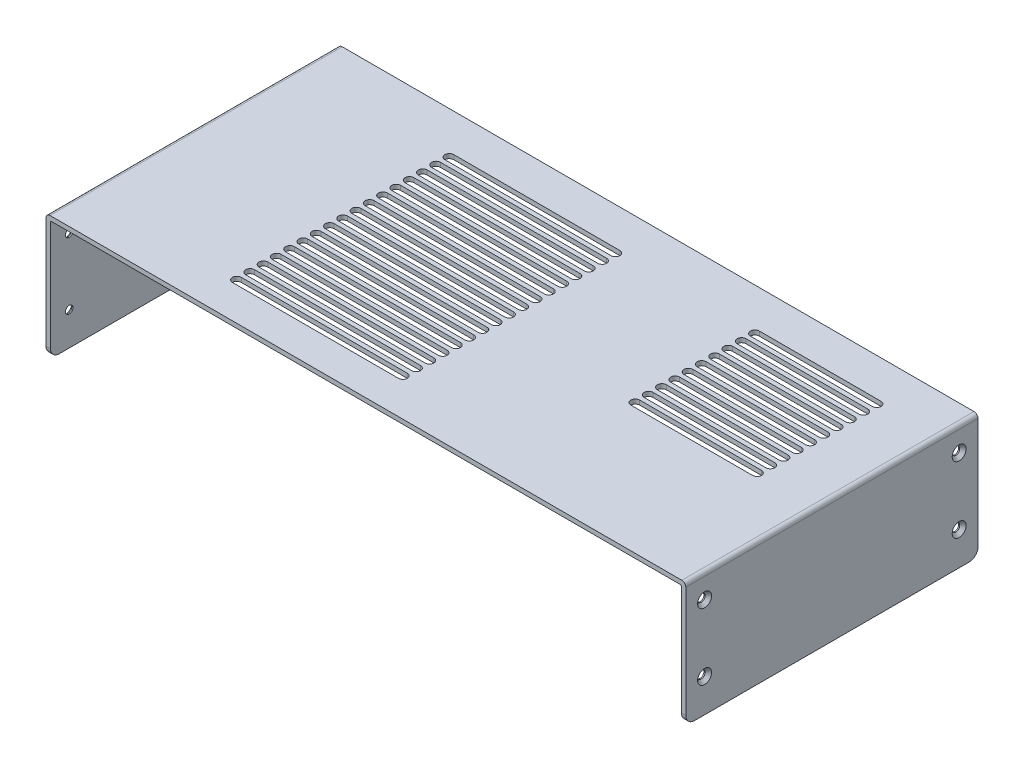
from build123d import *

# Parameters (mm, degrees)
BOSS_EXTRUDE1_DEPTH                             = 132
CSK_FOR_M3_FLAT_HEAD_MACHINE_SCREW1_D           = 3.4
CSK_FOR_M3_FLAT_HEAD_MACHINE_SCREW1_DEPTH       = 5
CSK_FOR_M3_FLAT_HEAD_MACHINE_SCREW1_CSINK_D     = 6.3
CSK_FOR_M3_FLAT_HEAD_MACHINE_SCREW1_CSINK_ANGLE = 90
CSK_FOR_M3_FLAT_HEAD_MACHINE_SCREW1_TIP         = 1.021463052
CSK_FOR_M3_FLAT_HEAD_MACHINE_SCREW2_D           = 3.4
CSK_FOR_M3_FLAT_HEAD_MACHINE_SCREW2_DEPTH       = 5
CSK_FOR_M3_FLAT_HEAD_MACHINE_SCREW2_CSINK_D     = 6.3
CSK_FOR_M3_FLAT_HEAD_MACHINE_SCREW2_CSINK_ANGLE = 90
CSK_FOR_M3_FLAT_HEAD_MACHINE_SCREW2_TIP         = 1.021463052
CUT_EXTRUDE1_DEPTH                              = 5
LPATTERN1_COUNT                                 = 17
LPATTERN1_PITCH                                 = 6
CUT_EXTRUDE2_DEPTH                              = 200
LPATTERN2_COUNT                                 = 10
LPATTERN2_PITCH                                 = 6
FILLET1_R                                       = 4


with BuildPart() as part:
    # Sketch1 → Boss-Extrude1 (new body)
    with BuildSketch(Plane.XY):
        with BuildLine():
            Line((0, 0), (-2, 0))
            Line((-2, 0), (-2, 54.2))
            ThreePointArc((-2, 54.2), (-1.472792206, 55.472792206), (-0.2, 56))
            Line((-0.2, 56), (285.2, 56))
            ThreePointArc((285.2, 56), (286.472792206, 55.472792206), (287, 54.2))
            Line((287, 54.2), (287, 0))
            Line((287, 0), (285, 0))
            Line((285, 0), (285, 53.5))
            ThreePointArc((285, 53.5), (284.853553391, 53.853553391), (284.5, 54))
            Line((284.5, 54), (0.5, 54))
            ThreePointArc((0.5, 54), (0.146446609, 53.853553391), (0, 53.5))
            Line((0, 53.5), (0, 0))
        make_face()
    extrude(amount=BOSS_EXTRUDE1_DEPTH)

    # CSK for M3 Flat Head Machine Screw1
    with Locations(Plane.ZY.offset(2)):
        with Locations((8.5, 45), (8.5, 15), (123.5, 45), (123.5, 15)):
            CounterSinkHole(CSK_FOR_M3_FLAT_HEAD_MACHINE_SCREW1_D / 2, CSK_FOR_M3_FLAT_HEAD_MACHINE_SCREW1_CSINK_D / 2, depth=CSK_FOR_M3_FLAT_HEAD_MACHINE_SCREW1_DEPTH, counter_sink_angle=CSK_FOR_M3_FLAT_HEAD_MACHINE_SCREW1_CSINK_ANGLE)
            with Locations((0, 0, -(CSK_FOR_M3_FLAT_HEAD_MACHINE_SCREW1_DEPTH + CSK_FOR_M3_FLAT_HEAD_MACHINE_SCREW1_TIP / 2))):  # 118° drill point
                Cone(0, CSK_FOR_M3_FLAT_HEAD_MACHINE_SCREW1_D / 2, CSK_FOR_M3_FLAT_HEAD_MACHINE_SCREW1_TIP, mode=Mode.SUBTRACT)

    # CSK for M3 Flat Head Machine Screw2
    with Locations(Plane(origin=(287, 0, 0), x_dir=(0, 0, -1), z_dir=(1, 0, 0))):
        with Locations((-123.5, 45), (-123.5, 15), (-8.5, 45), (-8.5, 15)):
            CounterSinkHole(CSK_FOR_M3_FLAT_HEAD_MACHINE_SCREW2_D / 2, CSK_FOR_M3_FLAT_HEAD_MACHINE_SCREW2_CSINK_D / 2, depth=CSK_FOR_M3_FLAT_HEAD_MACHINE_SCREW2_DEPTH, counter_sink_angle=CSK_FOR_M3_FLAT_HEAD_MACHINE_SCREW2_CSINK_ANGLE)
            with Locations((0, 0, -(CSK_FOR_M3_FLAT_HEAD_MACHINE_SCREW2_DEPTH + CSK_FOR_M3_FLAT_HEAD_MACHINE_SCREW2_TIP / 2))):  # 118° drill point
                Cone(0, CSK_FOR_M3_FLAT_HEAD_MACHINE_SCREW2_D / 2, CSK_FOR_M3_FLAT_HEAD_MACHINE_SCREW2_TIP, mode=Mode.SUBTRACT)

    # Sketch6 → Cut-Extrude1 (cut)
    with BuildSketch(Plane(origin=(0, 56, 0), x_dir=(1, 0, 0), z_dir=(0, 1, 0))):
        with BuildLine():
            Line((67.2, -17), (142.2, -17))
            ThreePointArc((142.2, -17), (144.2, -19), (142.2, -21))
            Line((142.2, -21), (67.2, -21))
            ThreePointArc((67.2, -21), (65.2, -19), (67.2, -17))
        make_face()
    cut_extrude1 = extrude(amount=-CUT_EXTRUDE1_DEPTH, mode=Mode.SUBTRACT)

    # LPattern1: Cut-Extrude1 ×17
    with Locations(*[(0, 0, i * LPATTERN1_PITCH) for i in range(1, LPATTERN1_COUNT)]):
        add(cut_extrude1, mode=Mode.SUBTRACT)

    # Sketch7 → Cut-Extrude2 (cut)
    with BuildSketch(Plane(origin=(0, 56, 0), x_dir=(1, 0, 0), z_dir=(0, 1, 0))):
        with BuildLine():
            Line((205.2, -17), (260.2, -17))
            ThreePointArc((260.2, -17), (262.2, -19), (260.2, -21))
            Line((260.2, -21), (205.2, -21))
            ThreePointArc((205.2, -21), (203.2, -19), (205.2, -17))
        make_face()
    cut_extrude2 = extrude(amount=-CUT_EXTRUDE2_DEPTH, mode=Mode.SUBTRACT)

    # LPattern2: Cut-Extrude2 ×10
    with Locations(*[(0, 0, i * LPATTERN2_PITCH) for i in range(1, LPATTERN2_COUNT)]):
        add(cut_extrude2, mode=Mode.SUBTRACT)

    # Fillet1
    fillet1_edges = [part.edges().sort_by_distance(p)[0] for p in [
        (-1, 0, 0),
        (286, 0, 0),
        (286, 0, 132),
        (-1, 0, 132),
    ]]
    fillet(fillet1_edges, radius=FILLET1_R)


solid = part.part
